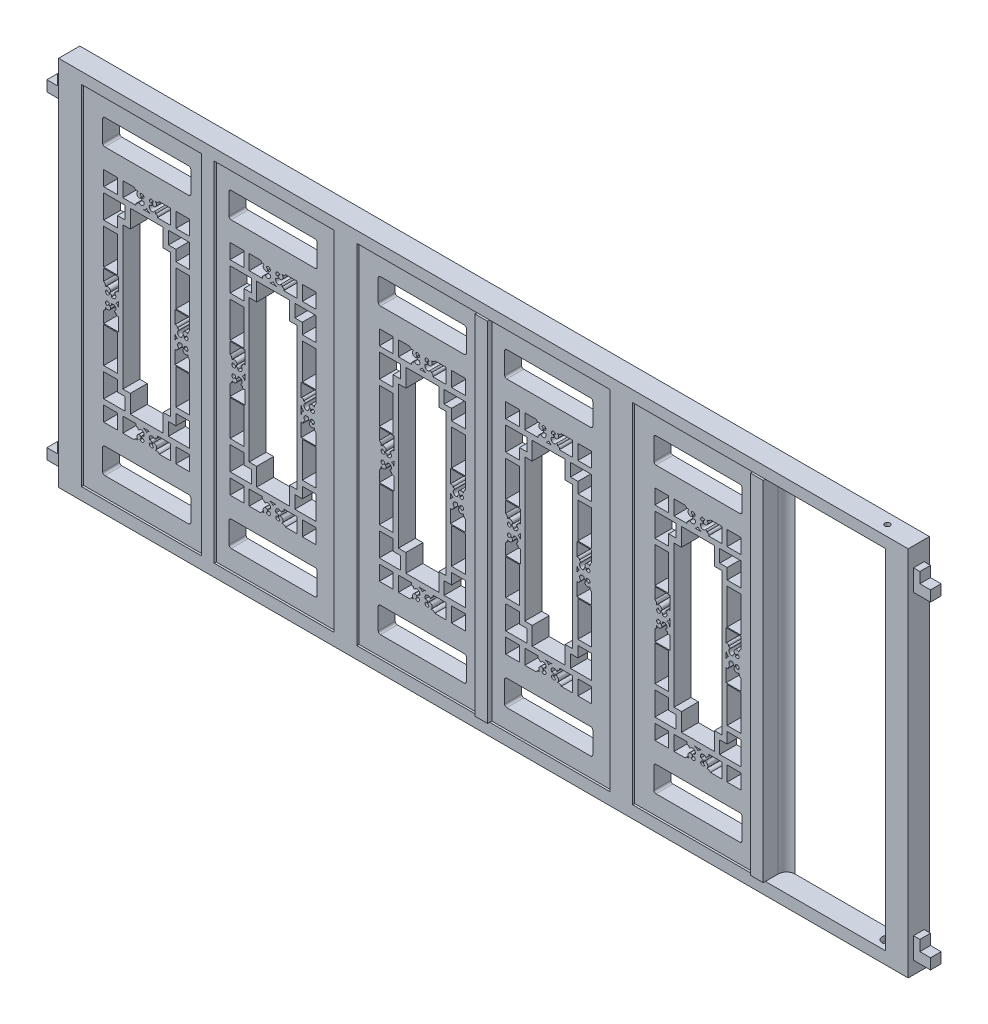
from build123d import *

# Parameters (mm, degrees)
SKETCH1_W                = 595
SKETCH1_H                = 1640
BOSS_EXTRUDE1_DEPTH      = 180
SKETCH_6_W               = 595
SKETCH_6_H               = 1640
CUT_EXTRUDE_2_DEPTH      = 100
CUT_EXTRUDE_3_DEPTH      = 100
SKETCH2_W                = 65
SKETCH2_H                = 70
SKETCH2_H_2              = 167
CUT_EXTRUDE_5_DEPTH      = 81
CUT_EXTRUDE_8_DEPTH      = 81
PATTERN_LINEAR_1_COUNT   = 2
PATTERN_LINEAR_1_PITCH   = 595
SKETCH_7_W               = 4000
SKETCH_7_H               = 1750
SKETCH_7_W_2             = 1190
SKETCH_7_H_2             = 1640
EXTRUDE_2_DEPTH          = 90
EXTRUDE_2_DEPTH_BACK     = 10
EXTRUDE_3_DEPTH          = 10
EXTRUDE_3_DEPTH_BACK     = 90
SKETCH_9_W               = 60
SKETCH_9_H               = 1640
EXTRUDE_4_DEPTH          = 100
PATTERN_LINEAR_2_COUNT   = 3
PATTERN_LINEAR_2_PITCH   = 1297.5
SKETCH_11_W              = 2595
SKETCH_11_H              = 1750
CUT_EXTRUDE_9_DEPTH      = 111
SKETCH_12_W              = 50
SKETCH_12_H              = 100
EXTRUDE_5_DEPTH          = 80
SKETCH_13_W              = 50
SKETCH_13_H              = 50
CUT_EXTRUDE_10_DEPTH     = 50
PATTERN_LINEAR_3_COUNT   = 2
PATTERN_LINEAR_3_PITCH   = 1500
MIRROR_4_COPY_1_SKETCH_W = 50
MIRROR_4_COPY_1_SKETCH_H = 100
MIRROR_4_COPY_1_DEPTH    = 80
MIRROR_4_COPY_2_SKETCH_W = 50
MIRROR_4_COPY_2_SKETCH_H = 50
MIRROR_4_COPY_2_DEPTH    = 50
SKETCH_15_W              = 565
SKETCH_15_H              = 1640
CUT_EXTRUDE_12_DEPTH     = 101
SKETCH_16_R              = 25
CUT_EXTRUDE_13_DEPTH     = 25
SKETCH_17_R              = 12.5
CUT_EXTRUDE_14_DEPTH     = 1751
EXTRUDE_6_DEPTH          = 1640


with BuildPart() as part:
    # Sketch1 → Boss-Extrude1 (new body)
    with BuildSketch(Plane.XY):
        with Locations((297.5, 820)):
            Rectangle(SKETCH1_W, SKETCH1_H)
    extrude(amount=BOSS_EXTRUDE1_DEPTH)

    # Sketch 6 → Cut-Extrude 2 (cut)
    with BuildSketch(Plane.XY.offset(180)):
        with Locations((297.5, 820)):
            Rectangle(SKETCH_6_W, SKETCH_6_H)
    extrude(amount=-CUT_EXTRUDE_2_DEPTH, mode=Mode.SUBTRACT)

    # Sketch 1 → Cut-Extrude 3 (cut)
    with BuildSketch(Plane(origin=(0, 0, 0), x_dir=(-1, 0, 0), z_dir=(0, 0, -1))):
        with BuildLine():
            ThreePointArc((-339.478697135, 363.442307012), (-347.464207716, 366.462464977), (-347.449072001, 375))
            Line((-347.449072001, 375), (-410, 375))
            Line((-410, 375), (-410, 305))
            Line((-410, 305), (-356.673331708, 305))
            ThreePointArc((-356.673331708, 305), (-348.94904931, 312.012889726), (-338.529552639, 312.541330816))
            ThreePointArc((-338.529552639, 312.541330816), (-344.046220029, 325.924483031), (-334.768909443, 337.036363636))
            ThreePointArc((-334.768909443, 337.036363636), (-323.949287324, 331.726907665), (-329.315168468, 320.935157804))
            ThreePointArc((-329.315168468, 320.935157804), (-314.478603669, 315.069270244), (-315.214046212, 331.006378394))
            ThreePointArc((-315.214046212, 331.006378394), (-318.365986632, 330.765395418), (-320.358708006, 328.311447022))
            ThreePointArc((-320.358708006, 328.311447022), (-320.882047686, 338.069212343), (-311.577227356, 341.053870966))
            ThreePointArc((-311.577227356, 341.053870966), (-311.192434776, 341.798442865), (-310.72696898, 342.495432272))
            ThreePointArc((-310.72696898, 342.495432272), (-316.343126273, 360.498534643), (-334.477239272, 355.321000146))
            ThreePointArc((-334.477239272, 355.321000146), (-338.751843962, 358.289222889), (-339.478697135, 363.442307012))
        make_face()
        with BuildLine():
            Line((-185, 375), (-247.550927999, 375))
            ThreePointArc((-247.550927999, 375), (-247.535792284, 366.462464977), (-255.521302865, 363.442307012))
            ThreePointArc((-255.521302865, 363.442307012), (-256.248156038, 358.289222889), (-260.522760728, 355.321000146))
            ThreePointArc((-260.522760728, 355.321000146), (-278.656873727, 360.498534643), (-284.27303102, 342.495432272))
            ThreePointArc((-284.27303102, 342.495432272), (-283.807565224, 341.798442865), (-283.422772644, 341.053870966))
            ThreePointArc((-283.422772644, 341.053870966), (-274.117952314, 338.069212343), (-274.641291994, 328.311447022))
            ThreePointArc((-274.641291994, 328.311447022), (-276.634013368, 330.765395418), (-279.785953788, 331.006378394))
            ThreePointArc((-279.785953788, 331.006378394), (-280.521396331, 315.069270244), (-265.684831532, 320.935157804))
            ThreePointArc((-265.684831532, 320.935157804), (-271.050712676, 331.726907665), (-260.231090557, 337.036363636))
            ThreePointArc((-260.231090557, 337.036363636), (-250.953779971, 325.924483031), (-256.470447361, 312.541330816))
            ThreePointArc((-256.470447361, 312.541330816), (-246.05095069, 312.012889726), (-238.326668292, 305))
            Line((-238.326668292, 305), (-185, 305))
            Line((-185, 305), (-185, 375))
        make_face()
        with BuildLine():
            ThreePointArc((-279.5, 375), (-290.126074317, 371.412833197), (-297.5, 362.9626))
            ThreePointArc((-297.5, 362.9626), (-304.873925683, 371.412833197), (-315.5, 375))
            Line((-315.5, 375), (-279.5, 375))
        make_face()
    cut_extrude_3 = extrude(amount=-CUT_EXTRUDE_3_DEPTH, mode=Mode.SUBTRACT)

    # Sketch2 → Cut-Extrude 5 (cut, through all)
    with BuildSketch(Plane(origin=(0, 0, 0), x_dir=(-1, 0, 0), z_dir=(0, 0, -1))):
        with BuildLine():
            Line((-100, 90), (-495, 90))
            ThreePointArc((-495, 90), (-502.071067812, 92.928932188), (-505, 100))
            Line((-505, 100), (-505, 200))
            ThreePointArc((-505, 200), (-502.071067812, 207.071067812), (-495, 210))
            Line((-495, 210), (-100, 210))
            ThreePointArc((-100, 210), (-92.928932188, 207.071067812), (-90, 200))
            Line((-90, 200), (-90, 100))
            ThreePointArc((-90, 100), (-92.928932188, 92.928932188), (-100, 90))
        make_face()
        with Locations((-467.5, 340)):
            Rectangle(SKETCH2_W, SKETCH2_H)
        with Locations((-127.5, 340)):
            Rectangle(SKETCH2_W, SKETCH2_H)
        Polygon((-435, 511), (-500, 511), (-500, 400), (-400, 400), (-400, 460), (-435, 460), align=None)
        Polygon((-195, 460), (-195, 400), (-95, 400), (-95, 511), (-160, 511), (-160, 460), align=None)
        with Locations((-467.5, 619.5)):
            Rectangle(SKETCH2_W, SKETCH2_H_2)
        with Locations((-127.5, 619.5)):
            Rectangle(SKETCH2_W, SKETCH2_H_2)
        Polygon((-220, 1240), (-375, 1240), (-375, 1155), (-410, 1155), (-410, 485), (-375, 485), (-375, 400), (-220, 400), (-220, 485), (-185, 485), (-185, 1155), (-220, 1155), align=None)
        with Locations((-467.5, 1020.5)):
            Rectangle(SKETCH2_W, SKETCH2_H_2)
        with Locations((-127.5, 1020.5)):
            Rectangle(SKETCH2_W, SKETCH2_H_2)
        Polygon((-95, 1240), (-195, 1240), (-195, 1180), (-160, 1180), (-160, 1129), (-95, 1129), align=None)
        with Locations((-127.5, 1300)):
            Rectangle(SKETCH2_W, SKETCH2_H)
        with Locations((-467.5, 1300)):
            Rectangle(SKETCH2_W, SKETCH2_H)
        Polygon((-400, 1240), (-500, 1240), (-500, 1129), (-435, 1129), (-435, 1180), (-400, 1180), align=None)
        with BuildLine():
            Line((-495, 1430), (-100, 1430))
            ThreePointArc((-100, 1430), (-92.928932188, 1432.928932188), (-90, 1440))
            Line((-90, 1440), (-90, 1540))
            ThreePointArc((-90, 1540), (-92.928932188, 1547.071067812), (-100, 1550))
            Line((-100, 1550), (-495, 1550))
            ThreePointArc((-495, 1550), (-502.071067812, 1547.071067812), (-505, 1540))
            Line((-505, 1540), (-505, 1440))
            ThreePointArc((-505, 1440), (-502.071067812, 1432.928932188), (-495, 1430))
        make_face()
    extrude(amount=-CUT_EXTRUDE_5_DEPTH, mode=Mode.SUBTRACT)

    # Mirror 1: Cut-Extrude 3 across plane
    add(cut_extrude_3.mirror(Plane.ZX.offset(820)), mode=Mode.SUBTRACT)

    # Sketch 1_5 → Cut-Extrude 8 (cut, through all)
    with BuildSketch(Plane(origin=(0, 0, 0), x_dir=(-1, 0, 0), z_dir=(0, 0, -1))):
        with BuildLine():
            Line((-430, 869.949072001), (-430, 932.5))
            Line((-430, 932.5), (-500, 932.5))
            Line((-500, 932.5), (-500, 879.173331708))
            ThreePointArc((-500, 879.173331708), (-492.987110274, 871.44904931), (-492.458669184, 861.029552639))
            ThreePointArc((-492.458669184, 861.029552639), (-479.075516969, 866.546220029), (-467.963636364, 857.268909443))
            ThreePointArc((-467.963636364, 857.268909443), (-473.273092335, 846.449287324), (-484.064842196, 851.815168468))
            ThreePointArc((-484.064842196, 851.815168468), (-489.930729756, 836.978603669), (-473.993621606, 837.714046212))
            ThreePointArc((-473.993621606, 837.714046212), (-474.234604582, 840.865986631), (-476.688552978, 842.858708006))
            ThreePointArc((-476.688552978, 842.858708006), (-466.930787657, 843.382047686), (-463.946129034, 834.077227356))
            ThreePointArc((-463.946129034, 834.077227356), (-463.201557135, 833.692434776), (-462.504567728, 833.22696898))
            ThreePointArc((-462.504567728, 833.22696898), (-444.501465357, 838.843126273), (-449.678999854, 856.977239272))
            ThreePointArc((-449.678999854, 856.977239272), (-446.710777111, 861.251843962), (-441.557692988, 861.978697135))
            ThreePointArc((-441.557692988, 861.978697135), (-438.537535023, 869.964207716), (-430, 869.949072001))
        make_face()
        with BuildLine():
            Line((-500, 760.826668292), (-500, 707.5))
            Line((-500, 707.5), (-430, 707.5))
            Line((-430, 707.5), (-430, 770.050927999))
            ThreePointArc((-430, 770.050927999), (-438.537535023, 770.035792284), (-441.557692988, 778.021302865))
            ThreePointArc((-441.557692988, 778.021302865), (-446.710777111, 778.748156038), (-449.678999854, 783.022760728))
            ThreePointArc((-449.678999854, 783.022760728), (-444.501465357, 801.156873727), (-462.504567728, 806.77303102))
            ThreePointArc((-462.504567728, 806.77303102), (-463.201557135, 806.307565224), (-463.946129034, 805.922772644))
            ThreePointArc((-463.946129034, 805.922772644), (-466.930787657, 796.617952314), (-476.688552978, 797.141291994))
            ThreePointArc((-476.688552978, 797.141291994), (-474.234604582, 799.134013368), (-473.993621606, 802.285953788))
            ThreePointArc((-473.993621606, 802.285953788), (-489.930729756, 803.021396331), (-484.064842196, 788.184831532))
            ThreePointArc((-484.064842196, 788.184831532), (-473.273092335, 793.550712676), (-467.963636364, 782.731090557))
            ThreePointArc((-467.963636364, 782.731090557), (-479.075516969, 773.453779971), (-492.458669184, 778.970447361))
            ThreePointArc((-492.458669184, 778.970447361), (-492.987110274, 768.55095069), (-500, 760.826668292))
        make_face()
        with BuildLine():
            ThreePointArc((-442.0374, 820), (-433.587166803, 827.373925683), (-430, 838))
            Line((-430, 838), (-430, 802))
            ThreePointArc((-430, 802), (-433.587166803, 812.626074317), (-442.0374, 820))
        make_face()
    cut_extrude_8 = extrude(amount=-CUT_EXTRUDE_8_DEPTH, mode=Mode.SUBTRACT)

    # Mirror 3: Cut-Extrude 8 across plane
    add(cut_extrude_8.mirror(Plane.ZY.offset(-297.5)), mode=Mode.SUBTRACT)


with BuildPart() as pattern_linear_1_1:
    # Pattern Linear 1: pattern copy
    add(part.part.moved(Location(Vector(1, 0, 0) * (1 * PATTERN_LINEAR_1_PITCH))))


with BuildPart() as part_1:
    add(part.part)

    add(pattern_linear_1_1.part)  # Extrude 2 merges Pattern Linear 1_1
    # Sketch 7 → Extrude 2 (add, two sides)
    with BuildSketch(Plane.XY) as extrude_2_sk:
        with Locations((1892.5, 817.5)):
            Rectangle(SKETCH_7_W, SKETCH_7_H)
        with Locations((1892.5, 820)):
            Rectangle(SKETCH_7_W_2, SKETCH_7_H_2, mode=Mode.SUBTRACT)
        with Locations((595, 820)):
            Rectangle(SKETCH_7_W_2, SKETCH_7_H_2, mode=Mode.SUBTRACT)
        with Locations((3190, 820)):
            Rectangle(SKETCH_7_W_2, SKETCH_7_H_2, mode=Mode.SUBTRACT)
    extrude(amount=EXTRUDE_2_DEPTH)
    extrude(extrude_2_sk.sketch, amount=-EXTRUDE_2_DEPTH_BACK)

    # Sketch 8 → Extrude 3 (add, two sides)
    with BuildSketch(Plane(origin=(0, 0, 0), x_dir=(-1, 0, 0), z_dir=(0, 0, -1))) as extrude_3_sk:
        Polygon((-595, 1640), (-565, 1640), (-565, 0), (-625, 0), (-625, 1640), align=None)
    extrude(amount=EXTRUDE_3_DEPTH)
    extrude(extrude_3_sk.sketch, amount=-EXTRUDE_3_DEPTH_BACK)

    # Sketch 9 → Extrude 4 (add)
    with BuildSketch(Plane.XY):
        with Locations((1892.5, 820)):
            Rectangle(SKETCH_9_W, SKETCH_9_H)
        with Locations((3190, 820)):
            Rectangle(SKETCH_9_W, SKETCH_9_H)
    extrude(amount=EXTRUDE_4_DEPTH)


with BuildPart() as pattern_linear_2_1:
    # Pattern Linear 2: pattern copy
    add(part_1.part.moved(Location(Vector(1, 0, 0) * (1 * PATTERN_LINEAR_2_PITCH))))


with BuildPart() as pattern_linear_2_2:
    # Pattern Linear 2: pattern copy
    add(part_1.part.moved(Location(Vector(1, 0, 0) * (2 * PATTERN_LINEAR_2_PITCH))))


with BuildPart() as cut_extrude_9_tool:
    # Sketch 11 → Cut-Extrude 9 (new body, through all)
    with BuildSketch(Plane.XY.offset(100)):
        with Locations((5190, 817.5)):
            Rectangle(SKETCH_11_W, SKETCH_11_H)
    extrude(amount=-CUT_EXTRUDE_9_DEPTH)


with BuildPart() as pattern_linear_2_1_1:
    add(pattern_linear_2_1.part)

    # Cut-Extrude 9: cut by cut_extrude_9_tool
    add(cut_extrude_9_tool.part, mode=Mode.SUBTRACT)


with BuildPart() as pattern_linear_2_2_1:
    add(pattern_linear_2_2.part)

    # Cut-Extrude 9: cut by cut_extrude_9_tool
    add(cut_extrude_9_tool.part, mode=Mode.SUBTRACT)

    # Sketch 15 → Cut-Extrude 12 (cut, through all)
    with BuildSketch(Plane(origin=(0, 0, 0), x_dir=(-1, 0, 0), z_dir=(0, 0, -1))):
        with Locations((-3502.5, 820)):
            Rectangle(SKETCH_15_W, SKETCH_15_H)
    extrude(amount=-CUT_EXTRUDE_12_DEPTH, mode=Mode.SUBTRACT)


with BuildPart() as part_2:
    add(part_1.part)

    # Sketch 12 → Extrude 5 (add)
    with BuildSketch(Plane.ZY.offset(107.5)):
        with Locations((40, 52.5)):
            Rectangle(SKETCH_12_W, SKETCH_12_H)
    extrude_5 = extrude(amount=EXTRUDE_5_DEPTH)

    # Sketch 13 → Cut-Extrude 10 (cut)
    with BuildSketch(Plane.ZY.offset(187.5)):
        with Locations((40, 77.5)):
            Rectangle(SKETCH_13_W, SKETCH_13_H)
    cut_extrude_10 = extrude(amount=-CUT_EXTRUDE_10_DEPTH, mode=Mode.SUBTRACT)

    # Pattern Linear 3: Extrude 5, Cut-Extrude 10 ×2
    with Locations(*[(0, i * PATTERN_LINEAR_3_PITCH, 0) for i in range(1, PATTERN_LINEAR_3_COUNT)]):
        add(extrude_5)
        add(cut_extrude_10, mode=Mode.SUBTRACT)

    # Mirror 4: Extrude 5, Cut-Extrude 10 across plane
    add(extrude_5.mirror(Plane(origin=(1892.5, -57.5, 90), x_dir=(0, 0, 1), z_dir=(-1, 0, 0))))
    add(cut_extrude_10.mirror(Plane(origin=(1892.5, -57.5, 90), x_dir=(0, 0, 1), z_dir=(-1, 0, 0))), mode=Mode.SUBTRACT)

    # Mirror 4 copy 1 sketch → Mirror 4 copy 1 (add)
    with BuildSketch(Plane(origin=(3892.5, 1500, 0), x_dir=(0, 0, 1), z_dir=(1, 0, 0))):
        with Locations((40, -52.5)):
            Rectangle(MIRROR_4_COPY_1_SKETCH_W, MIRROR_4_COPY_1_SKETCH_H)
    extrude(amount=MIRROR_4_COPY_1_DEPTH)

    # Mirror 4 copy 2 sketch → Mirror 4 copy 2 (cut)
    with BuildSketch(Plane(origin=(3972.5, 1500, 0), x_dir=(0, 0, 1), z_dir=(1, 0, 0))):
        with Locations((40, -77.5)):
            Rectangle(MIRROR_4_COPY_2_SKETCH_W, MIRROR_4_COPY_2_SKETCH_H)
    extrude(amount=-MIRROR_4_COPY_2_DEPTH, mode=Mode.SUBTRACT)


with BuildPart() as cut_extrude_13_tool:
    # Sketch 16 → Cut-Extrude 13 (new body)
    with BuildSketch(Plane.XZ.offset(-1640)):
        with Locations((3745, 40)):
            Circle(SKETCH_16_R)
    cut_extrude_13 = extrude(amount=-CUT_EXTRUDE_13_DEPTH)


with BuildPart() as part_3:
    add(part_2.part)

    # Cut-Extrude 13: cut by cut_extrude_13_tool
    add(cut_extrude_13_tool.part, mode=Mode.SUBTRACT)


with BuildPart() as pattern_linear_2_1_2:
    add(pattern_linear_2_1_1.part)

    # Cut-Extrude 13: cut by cut_extrude_13_tool
    add(cut_extrude_13_tool.part, mode=Mode.SUBTRACT)


with BuildPart() as pattern_linear_2_2_2:
    add(pattern_linear_2_2_1.part)

    # Cut-Extrude 13: cut by cut_extrude_13_tool
    add(cut_extrude_13_tool.part, mode=Mode.SUBTRACT)


with BuildPart() as mirror_7_tool:
    # Mirror 7: Cut-Extrude 13 across plane
    add(cut_extrude_13.mirror(Plane.ZX.offset(820)))


with BuildPart() as part_4:
    add(part_3.part)

    # Mirror 7: cut by mirror_7_tool
    add(mirror_7_tool.part, mode=Mode.SUBTRACT)


with BuildPart() as pattern_linear_2_1_3:
    add(pattern_linear_2_1_2.part)

    # Mirror 7: cut by mirror_7_tool
    add(mirror_7_tool.part, mode=Mode.SUBTRACT)


with BuildPart() as pattern_linear_2_2_3:
    add(pattern_linear_2_2_2.part)

    # Mirror 7: cut by mirror_7_tool
    add(mirror_7_tool.part, mode=Mode.SUBTRACT)


with BuildPart() as cut_extrude_14_tool:
    # Sketch 17 → Cut-Extrude 14 (new body, through all)
    with BuildSketch(Plane(origin=(0, 1692.5, 0), x_dir=(1, 0, 0), z_dir=(0, 1, 0))):
        with Locations((3745, -40)):
            Circle(SKETCH_17_R)
    extrude(amount=-CUT_EXTRUDE_14_DEPTH)


with BuildPart() as part_5:
    add(part_4.part)

    # Cut-Extrude 14: cut by cut_extrude_14_tool
    add(cut_extrude_14_tool.part, mode=Mode.SUBTRACT)



with BuildPart() as pattern_linear_2_1_4:
    add(pattern_linear_2_1_3.part)

    # Cut-Extrude 14: cut by cut_extrude_14_tool
    add(cut_extrude_14_tool.part, mode=Mode.SUBTRACT)


with BuildPart() as pattern_linear_2_2_4:
    add(pattern_linear_2_2_3.part)

    # Cut-Extrude 14: cut by cut_extrude_14_tool
    add(cut_extrude_14_tool.part, mode=Mode.SUBTRACT)


with BuildPart() as part_6:
    add(part_5.part)

    add(pattern_linear_2_1_4.part)  # Extrude 6 merges Pattern Linear 2_1

    add(pattern_linear_2_2_4.part)  # Extrude 6 merges Pattern Linear 2_2
    # Sketch 18 → Extrude 6 (add)
    with BuildSketch(Plane(origin=(0, 0, 0), x_dir=(1, 0, 0), z_dir=(0, 1, 0))):
        with BuildLine():
            Line((3260, 10), (3220, 10))
            Line((3220, 10), (3220, 0))
            Line((3220, 0), (3220, -30))
            ThreePointArc((3220, -30), (3231.715728753, -1.715728753), (3260, 10))
        make_face()
    extrude(amount=EXTRUDE_6_DEPTH)


solid = part_6.part
